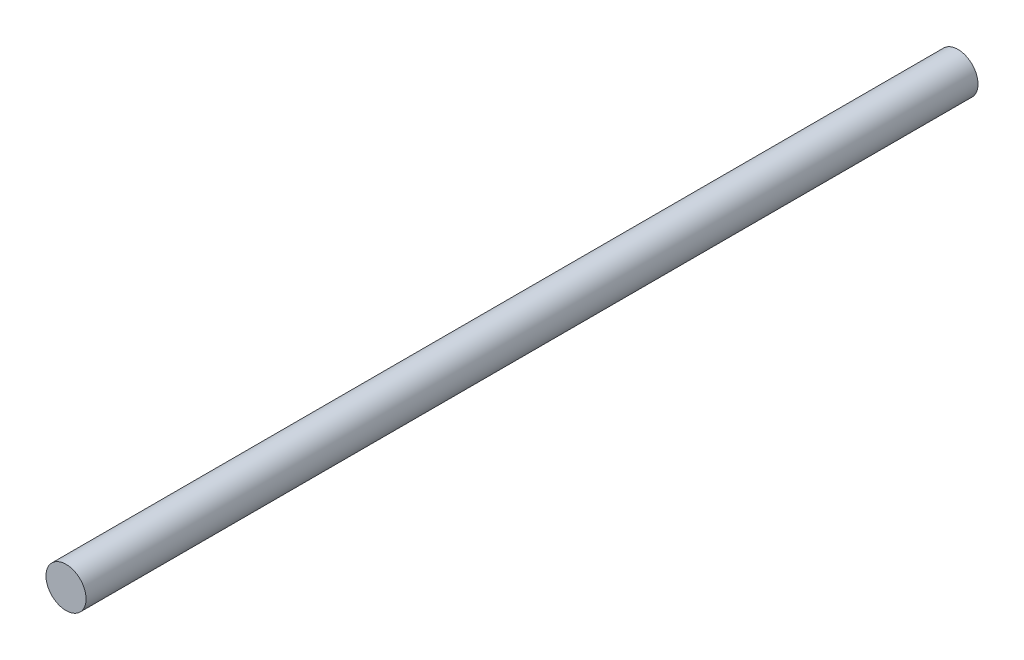
from build123d import *

# Parameters (mm, degrees)
SKETCH1_R           = 4
BOSS_EXTRUDE1_DEPTH = 88.9


with BuildPart() as part:
    # Sketch1 → Boss-Extrude1 (new body, symmetric)
    with BuildSketch(Plane.XY):
        Circle(SKETCH1_R)
    extrude(amount=BOSS_EXTRUDE1_DEPTH, both=True)


solid = part.part
